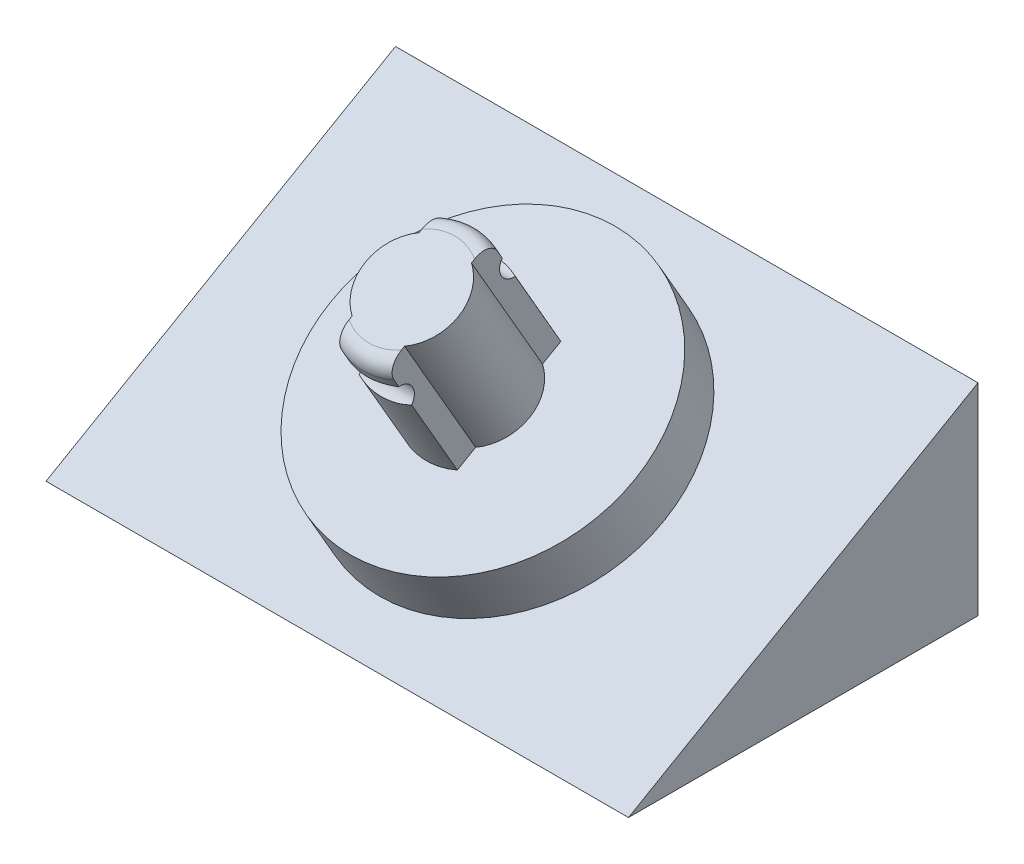
from build123d import *

# Parameters (mm, degrees)
BOSS_EXTRUDE4_DEPTH = 15
SKETCH3_R           = 7.86
BOSS_EXTRUDE2_DEPTH = 3
BOSS_EXTRUDE3_DEPTH = 7.32
SKETCH6_R           = 0.715
CUT_EXTRUDE2_DEPTH  = 17.35
FILLET5_R           = 0.8


with BuildPart() as part:
    # Sketch8 → Boss-Extrude4 (new body, symmetric)
    with BuildSketch(Plane(origin=(0, 0, 0), x_dir=(0, 0, -1), z_dir=(1, 0, 0))):
        Polygon((-9, 0), (9, 10.392304845), (9, 0), align=None)
    extrude(amount=BOSS_EXTRUDE4_DEPTH, both=True)

    # Sketch3 → Boss-Extrude2 (add)
    with BuildSketch(Plane(origin=(0, 1.640246968, 6.159008915), x_dir=(1, 0, 0), z_dir=(0, -0.866025404, -0.5))):
        with Locations((0, -7.11181091)):
            Circle(SKETCH3_R)
    extrude(amount=-BOSS_EXTRUDE2_DEPTH)

    # Sketch5 → Boss-Extrude3 (add)
    with BuildSketch(Plane(origin=(0, 6.495190528, 3.75), x_dir=(1, 0, 0), z_dir=(0, 0.866025404, 0.5))):
        with BuildLine():
            Line((1.35, 4.588434219), (1.35, 5.674941499))
            ThreePointArc((1.35, 5.674941499), (0, 5.958076211), (-1.35, 5.674941499))
            Line((-1.35, 5.674941499), (-1.35, 4.588434219))
            ThreePointArc((-1.35, 4.588434219), (-2.405, 2.598076211), (-1.35, 0.607718203))
            Line((-1.35, 0.607718203), (-1.35, -0.478789077))
            ThreePointArc((-1.35, -0.478789077), (0, -0.761923789), (1.35, -0.478789077))
            Line((1.35, -0.478789077), (1.35, 0.607718203))
            ThreePointArc((1.35, 0.607718203), (2.405, 2.598076211), (1.35, 4.588434219))
        make_face()
    extrude(amount=BOSS_EXTRUDE3_DEPTH)

    # Sketch6 → Cut-Extrude2 (cut, through all)
    with BuildSketch(Plane(origin=(1.35, 0, 0), x_dir=(0, 0, -1), z_dir=(1, 0, 0))):
        with Locations((-1.275154643, 14.124785052)):
            Circle(SKETCH6_R)
        with Locations((-7.094845357, 10.764785052)):
            Circle(SKETCH6_R)
    extrude(amount=-CUT_EXTRUDE2_DEPTH, mode=Mode.SUBTRACT)

    # Fillet5
    fillet5_edges = [part.edges().sort_by_distance(p)[0] for p in [
        (0, 12.45353459, 8.069845357),
        (0, 15.81353459, 2.250154643),
    ]]
    fillet(fillet5_edges, radius=FILLET5_R)


solid = part.part
